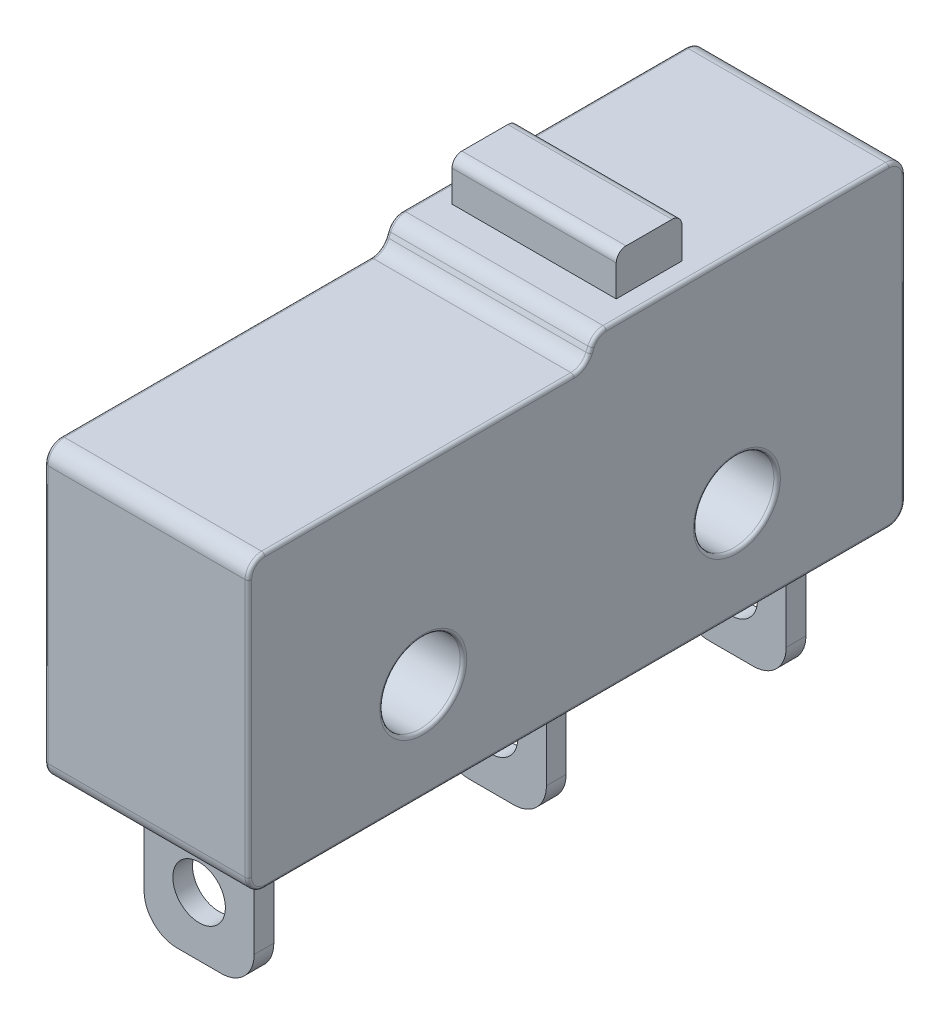
from build123d import *

# Parameters (mm, degrees)
BOSS_EXTRUDE1_DEPTH = 3.1
SKETCH2_R           = 1.225
CUT_EXTRUDE4_DEPTH  = 7.2
FILLET1_R           = 0.5
FILLET2_R           = 0.1
SKETCH3_W           = 3.35
SKETCH3_H           = 0.6
BOSS_EXTRUDE2_DEPTH = 4
SKETCH4_R           = 0.8
CUT_EXTRUDE5_DEPTH  = 19.4
FILLET3_R           = 1
BOSS_EXTRUDE3_DEPTH = 2.5


with BuildPart() as part:
    # Sketch1 → Boss-Extrude1 (new body, symmetric)
    with BuildSketch(Plane(origin=(0, 0, 0), x_dir=(0, 0, -1), z_dir=(1, 0, 0))):
        Polygon((10.562998325, 9.6), (10.25, 8.85), (0, 8.85), (0, 0), (20, 0), (20, 9.6), align=None)
    extrude(amount=BOSS_EXTRUDE1_DEPTH, both=True)

    # Sketch2 → Cut-Extrude4 (cut, through all)
    with BuildSketch(Plane(origin=(3.1, 0, 0), x_dir=(0, 0, -1), z_dir=(1, 0, 0))):
        with Locations((5.325, 2.975)):
            Circle(SKETCH2_R)
        with Locations((14.875, 2.975)):
            Circle(SKETCH2_R)
    extrude(amount=-CUT_EXTRUDE4_DEPTH, mode=Mode.SUBTRACT)

    # Fillet1
    fillet1_edges = [part.edges().sort_by_distance(p)[0] for p in [
        (0, 8.85, 0),
        (0, 8.85, -10.25),
        (0, 9.6, -10.562998325),
        (0, 9.6, -20),
        (0, 0, -20),
        (0, 0, 0),
    ]]
    fillet(fillet1_edges, radius=FILLET1_R)

    # Fillet2
    fillet2_edges = [part.edges().sort_by_distance(p)[0] for p in [
        (-3.1, 2.975, -4.1),
        (3.1, 2.975, -4.1),
        (-3.1, 2.975, -13.65),
        (3.1, 2.975, -13.65),
        (-3.1, 4.8, -20),
        (3.1, 4.8, -20),
        (-3.1, 4.425, 0),
        (-3.1, 8.85, -5.20843551),
        (-3.1, 9.225, -10.406499162),
        (-3.1, 9.6, -15.198063652),
        (-3.1, 0, -10),
        (-3.1, 8.703553391, -0.146446609),
        (-3.1, 0.146446609, -0.146446609),
        (-3.1, 9.516103622, -10.618894954),
        (-3.1, 9.453553391, -19.853553391),
        (-3.1, 0.146446609, -19.853553391),
        (3.1, 0, -10),
        (3.1, 4.425, 0),
        (3.1, 9.6, -15.198063652),
        (3.1, 9.225, -10.406499162),
        (3.1, 8.85, -5.20843551),
        (3.1, 8.703553391, -0.146446609),
        (3.1, 0.146446609, -0.146446609),
        (3.1, 9.516103622, -10.618894954),
        (3.1, 9.453553391, -19.853553391),
        (3.1, 0.146446609, -19.853553391),
        (-3.1, 8.933896378, -10.194103371),
        (3.1, 8.933896378, -10.194103371),
    ]]
    fillet(fillet2_edges, radius=FILLET2_R)

    # Sketch3 → Boss-Extrude2 (add)
    with BuildSketch(Plane.XZ):
        with Locations((0, -1.9)):
            Rectangle(SKETCH3_W, SKETCH3_H)
        with Locations((0, -10.8)):
            Rectangle(SKETCH3_W, SKETCH3_H)
        with Locations((0, -18.1)):
            Rectangle(SKETCH3_W, SKETCH3_H)
    extrude(amount=BOSS_EXTRUDE2_DEPTH)

    # Sketch4 → Cut-Extrude5 (cut, through all)
    with BuildSketch(Plane(origin=(0, 0, -18.4), x_dir=(-1, 0, 0), z_dir=(0, 0, -1))):
        with Locations((0, -2.2)):
            Circle(SKETCH4_R)
    extrude(amount=-CUT_EXTRUDE5_DEPTH, mode=Mode.SUBTRACT)

    # Fillet3
    fillet3_edges = [part.edges().sort_by_distance(p)[0] for p in [
        (-1.675, -4, -1.9),
        (1.675, -4, -1.9),
        (-1.675, -4, -10.8),
        (1.675, -4, -10.8),
        (-1.675, -4, -18.1),
        (1.675, -4, -18.1),
    ]]
    fillet(fillet3_edges, radius=FILLET3_R)

    # Sketch5 → Boss-Extrude3 (add, symmetric)
    with BuildSketch(Plane(origin=(0, 0, 0), x_dir=(0, 0, -1), z_dir=(1, 0, 0))):
        with BuildLine():
            Line((11.8, 9.6), (11.8, 10.55))
            ThreePointArc((11.8, 10.55), (11.887867966, 10.762132034), (12.1, 10.85))
            Line((12.1, 10.85), (13.5, 10.85))
            ThreePointArc((13.5, 10.85), (13.712132034, 10.762132034), (13.8, 10.55))
            Line((13.8, 10.55), (13.8, 9.6))
            Line((13.8, 9.6), (11.8, 9.6))
        make_face()
    extrude(amount=BOSS_EXTRUDE3_DEPTH, both=True)


solid = part.part
